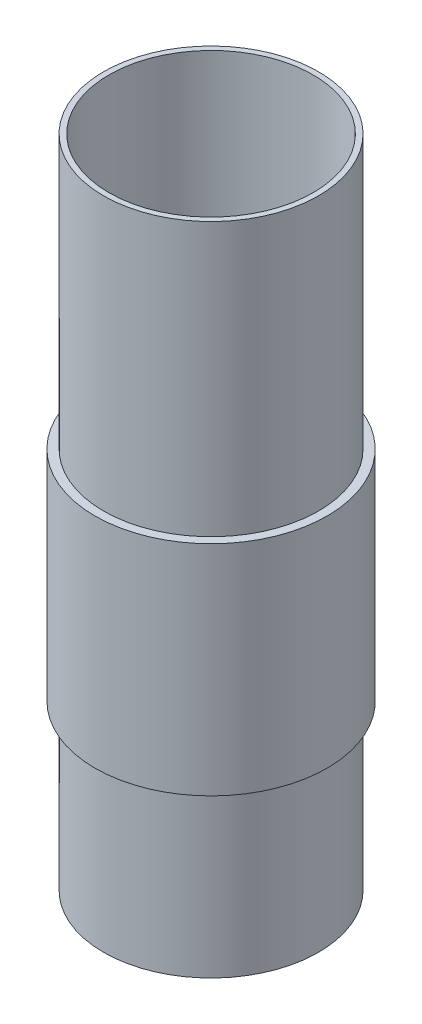
from build123d import *

# Parameters (mm, degrees)
SKETCH1_R           = 25.0063
SKETCH1_R_2         = 23.749
BOSS_EXTRUDE1_DEPTH = 152.4
SKETCH5_R           = 27.0002
SKETCH5_R_2         = 25.0063
BOSS_EXTRUDE3_DEPTH = 50.8


with BuildPart() as part:
    # Sketch1 → Boss-Extrude1 (new body)
    with BuildSketch(Plane(origin=(0, 0, 0), x_dir=(1, 0, 0), z_dir=(0, 1, 0))):
        Circle(SKETCH1_R)
        Circle(SKETCH1_R_2, mode=Mode.SUBTRACT)
    extrude(amount=BOSS_EXTRUDE1_DEPTH)

    # Sketch5 → Boss-Extrude3 (add)
    with BuildSketch(Plane(origin=(0, 88.9, 0), x_dir=(1, 0, 0), z_dir=(0, 1, 0))):
        Circle(SKETCH5_R)
        Circle(SKETCH5_R_2, mode=Mode.SUBTRACT)
    extrude(amount=-BOSS_EXTRUDE3_DEPTH)


solid = part.part
